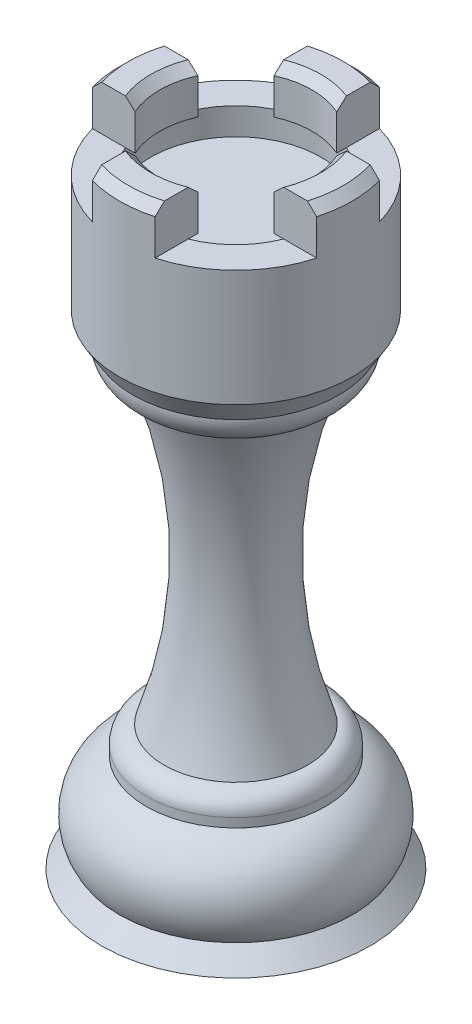
from build123d import *

# Parameters (mm, degrees)
CUT_EXTRUDE1_DEPTH = 5
SKETCH3_R          = 8.5
CUT_EXTRUDE2_DEPTH = 5
SKETCH5_R          = 9.5
CUT_EXTRUDE3_DEPTH = 3
CHAMFER1_SIZE      = 1


with BuildPart() as part:
    # Sketch1 → Revolve2 (revolve)
    with BuildSketch(Plane.XY, mode=Mode.PRIVATE) as revolve2_sk:
        with BuildLine():
            Line((0, -13.216216216), (0, 58.773783784))
            Line((0, 58.773783784), (-13, 58.773783784))
            Line((-13, 58.773783784), (-13, 40.773783784))
            Line((-13, 40.773783784), (-11.5, 38.273783784))
            ThreePointArc((-11.5, 38.273783784), (-10.687594514, 35.99246344), (-8.5, 34.953783784))
            ThreePointArc((-8.5, 34.953783784), (-5.234654729, 17.897867779), (-8, 0.753783784))
            ThreePointArc((-8, 0.753783784), (-9.414213562, 0.167997346), (-10, -1.246216216))
            Line((-10, -1.246216216), (-10, -2.246216216))
            ThreePointArc((-10, -2.246216216), (-13.688325627, -5.999334736), (-13, -11.216216216))
            Line((-13, -11.216216216), (-15, -13.216216216))
            Line((-15, -13.216216216), (0, -13.216216216))
        make_face()
    revolve(revolve2_sk.sketch.rotate(Axis((0, 81.004684333, 0), (0, -1, 0)), 270), axis=Axis((0, 81.004684333, 0), (0, -1, 0)))

    # Sketch2 → Cut-Extrude1 (cut)
    with BuildSketch(Plane(origin=(0, 58.773783784, 0), x_dir=(1, 0, 0), z_dir=(0, 1, 0))):
        with BuildLine():
            Line((-3.5, 7.745966692), (-3.5, 12.519984026))
            ThreePointArc((-3.5, 12.519984026), (-9.192388155, 9.192388155), (-12.519984026, 3.5))
            Line((-12.519984026, 3.5), (-7.745966692, 3.5))
            ThreePointArc((-7.745966692, 3.5), (-6.01040764, 6.01040764), (-3.5, 7.745966692))
        make_face()
        with BuildLine():
            ThreePointArc((-12.519984026, -3.5), (-9.192388155, -9.192388155), (-3.5, -12.519984026))
            Line((-3.5, -12.519984026), (-3.5, -7.745966692))
            ThreePointArc((-3.5, -7.745966692), (-6.01040764, -6.01040764), (-7.745966692, -3.5))
            Line((-7.745966692, -3.5), (-12.519984026, -3.5))
        make_face()
        with BuildLine():
            ThreePointArc((3.5, -12.519984026), (9.192388155, -9.192388155), (12.519984026, -3.5))
            Line((12.519984026, -3.5), (7.745966692, -3.5))
            ThreePointArc((7.745966692, -3.5), (6.01040764, -6.01040764), (3.5, -7.745966692))
            Line((3.5, -7.745966692), (3.5, -12.519984026))
        make_face()
        with BuildLine():
            ThreePointArc((3.5, 7.745966692), (6.01040764, 6.01040764), (7.745966692, 3.5))
            Line((7.745966692, 3.5), (12.519984026, 3.5))
            ThreePointArc((12.519984026, 3.5), (9.192388155, 9.192388155), (3.5, 12.519984026))
            Line((3.5, 12.519984026), (3.5, 7.745966692))
        make_face()
    extrude(amount=-CUT_EXTRUDE1_DEPTH, mode=Mode.SUBTRACT)

    # Sketch3 → Cut-Extrude2 (cut)
    with BuildSketch(Plane(origin=(0, 58.773783784, 0), x_dir=(1, 0, 0), z_dir=(0, 1, 0))):
        Circle(SKETCH3_R)
    extrude(amount=-CUT_EXTRUDE2_DEPTH, mode=Mode.SUBTRACT)

    # Sketch5 → Cut-Extrude3 (cut)
    with BuildSketch(Plane(origin=(0, 53.773783784, 0), x_dir=(1, 0, 0), z_dir=(0, 1, 0))):
        with Locations(Location((0, 0, 0), (0, 0, 270))):
            Circle(SKETCH5_R)
    extrude(amount=-CUT_EXTRUDE3_DEPTH, mode=Mode.SUBTRACT)

    # Chamfer1
    chamfer1_edges = [part.edges().sort_by_distance(p)[0] for p in [
        (13, 58.773783784, 0),
        (0, 58.773783784, -13),
        (-13, 58.773783784, 0),
        (1.766381565, 58.773783784, 12.879436951),
        (8.5, 58.773783784, 0),
        (0, 58.773783784, -8.5),
        (-8.5, 58.773783784, 0),
        (0, 58.773783784, 8.5),
    ]]
    chamfer(chamfer1_edges, length=CHAMFER1_SIZE)


solid = part.part
